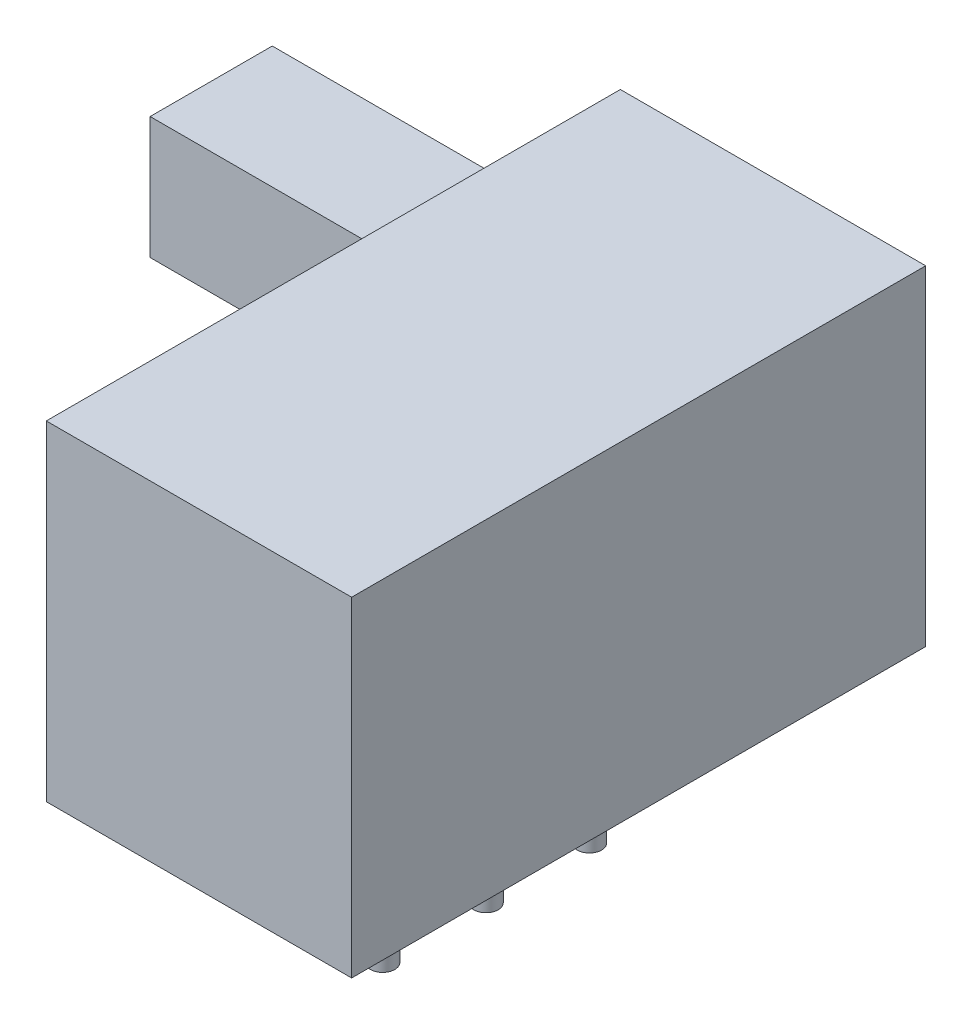
from build123d import *

# Parameters (mm, degrees)
SKETCH1_R             = 0.3
BOSS_EXTRUDE1_DEPTH   = 3.8
BOSS_EXTRUDE1_2_DEPTH = 3.8
BOSS_EXTRUDE1_3_DEPTH = 3.8
SKETCH2_W             = 7.5
SKETCH2_H             = 14.1
BOSS_EXTRUDE2_DEPTH   = 8.1
SKETCH3_W             = 3
SKETCH3_H             = 3
BOSS_EXTRUDE3_DEPTH   = 6


with BuildPart() as part:
    # Sketch1 → Boss-Extrude1 (new body)
    with BuildSketch(Plane(origin=(0, 0, 0), x_dir=(1, 0, 0), z_dir=(0, 1, 0))):
        Circle(SKETCH1_R)
    extrude(amount=-BOSS_EXTRUDE1_DEPTH)



with BuildPart() as body_2:
    # Sketch1 → Boss-Extrude1 2 (new body)
    with BuildSketch(Plane(origin=(0, 0, 0), x_dir=(1, 0, 0), z_dir=(0, 1, 0))):
        with Locations((0, -2.54)):
            Circle(SKETCH1_R)
    extrude(amount=-BOSS_EXTRUDE1_2_DEPTH)


with BuildPart() as body_3:
    # Sketch1 → Boss-Extrude1 3 (new body)
    with BuildSketch(Plane(origin=(0, 0, 0), x_dir=(1, 0, 0), z_dir=(0, 1, 0))):
        with Locations((0, 2.54)):
            Circle(SKETCH1_R)
    extrude(amount=-BOSS_EXTRUDE1_3_DEPTH)


with BuildPart() as part_1:
    add(part.part)

    add(body_2.part)  # Boss-Extrude2 merges body 2

    add(body_3.part)  # Boss-Extrude2 merges body 3
    # Sketch2 → Boss-Extrude2 (add)
    with BuildSketch(Plane(origin=(0, 0, 0), x_dir=(1, 0, 0), z_dir=(0, 1, 0))):
        Rectangle(SKETCH2_W, SKETCH2_H)
    extrude(amount=BOSS_EXTRUDE2_DEPTH)

    # Sketch3 → Boss-Extrude3 (add)
    with BuildSketch(Plane.ZY.offset(3.75)):
        with Locations((-3, 5.8)):
            Rectangle(SKETCH3_W, SKETCH3_H)
    extrude(amount=BOSS_EXTRUDE3_DEPTH)


solid = part_1.part
